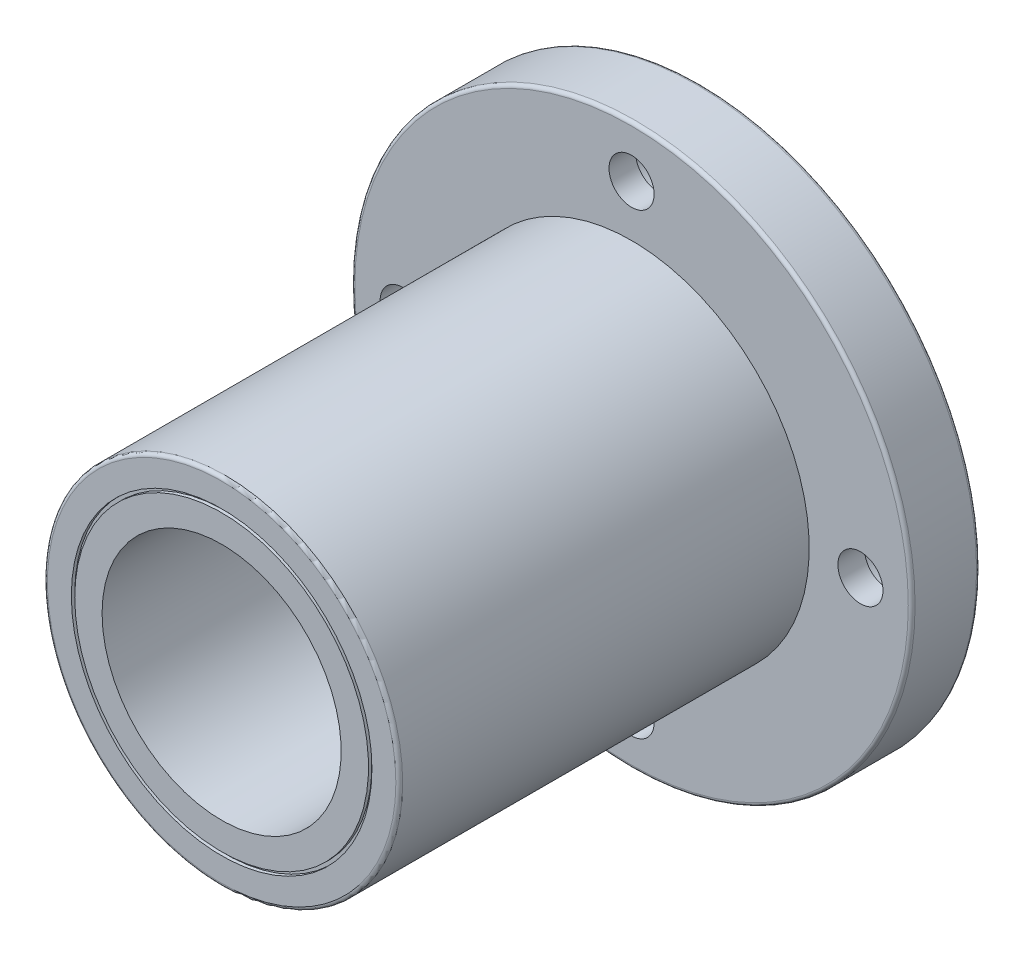
from build123d import *

# Parameters (mm, degrees)
PADR_OCIRCULAR1_COUNT = 4
FILETE1_R             = 0.5


with BuildPart() as part:
    # Esboço1 → Revolução1 (revolve)
    with BuildSketch(Plane(origin=(0, 0, 0), x_dir=(0, 0, -1), z_dir=(1, 0, 0)), mode=Mode.PRIVATE) as revolu_o1_sk:
        Polygon((0, 17.5), (0, 21.5), (-0.5, 21.5), (-0.5, 22), (0, 22), (0, 25.5), (-0.5, 25.5), (-0.5, 26), (0, 26), (0, 41), (-10, 41), (-10, 26), (-70, 26), (-70, 22), (-69.5, 22), (-69.5, 21.5), (-70, 21.5), (-70, 17.5), align=None)
    revolve(revolu_o1_sk.sketch.rotate(Axis((0, 0, 0), (0, 0, 1)), 90), axis=Axis((0, 0, 0), (0, 0, 1)))  # turned: the seam where the file's is

    # Esboço5 → Corte-Revolução1 (revolve, cut)
    with BuildSketch(Plane(origin=(0, 0, 0), x_dir=(0, 0, -1), z_dir=(1, 0, 0)), mode=Mode.PRIVATE) as corte_revolu_o1_sk:
        Polygon((0, 39), (-6.1, 39), (-6.1, 36.8), (-10, 36.8), (-10, 33.5), (0, 33.5), align=None)
    corte_revolu_o1 = revolve(corte_revolu_o1_sk.sketch.rotate(Axis((0, 33.5, 0), (0, 0, -1)), 180), axis=Axis((0, 33.5, 0), (0, 0, -1)), mode=Mode.SUBTRACT)  # turned: the seam where the file's is

    # PadrãoCircular1: Corte-Revolução1 ×4 about axis
    padr_ocircular1_axis = Axis((0, 0, 0), (0, 0, 1))
    for i in range(1, PADR_OCIRCULAR1_COUNT):
        add(corte_revolu_o1.rotate(padr_ocircular1_axis, i * 360 / PADR_OCIRCULAR1_COUNT), mode=Mode.SUBTRACT)

    # Filete1
    filete1_edges = [part.edges().sort_by_distance(p)[0] for p in [
        (26, 0, 70),
        (41, 0, 10),
        (41, 0, 0),
    ]]
    fillet(filete1_edges, radius=FILETE1_R)


solid = part.part
